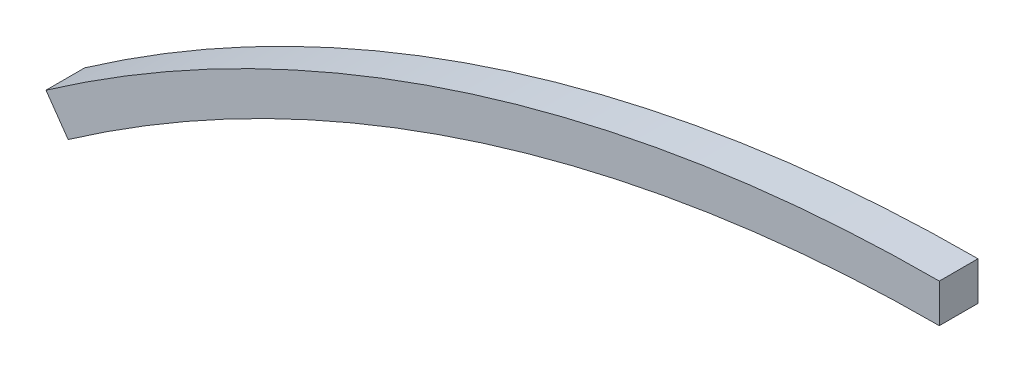
from build123d import *

# Parameters (mm, degrees)
BOSS_EXTRU_1_DEPTH = 2


with BuildPart() as part:
    # Esquisse1 → Boss.-Extru.1 (new body)
    with BuildSketch(Plane.XY):
        with BuildLine():
            Line((-46.207623312, 66.083421927), (-45.061543936, 64.444366692))
            ThreePointArc((-45.061543936, 64.444366692), (-23.621732331, 75.004219227), (0, 78.635991379))
            Line((0, 78.635991379), (0, 80.635991379))
            ThreePointArc((0, 80.635991379), (-24.222519118, 76.911850019), (-46.207623312, 66.083421927))
        make_face()
    extrude(amount=BOSS_EXTRU_1_DEPTH)


solid = part.part
